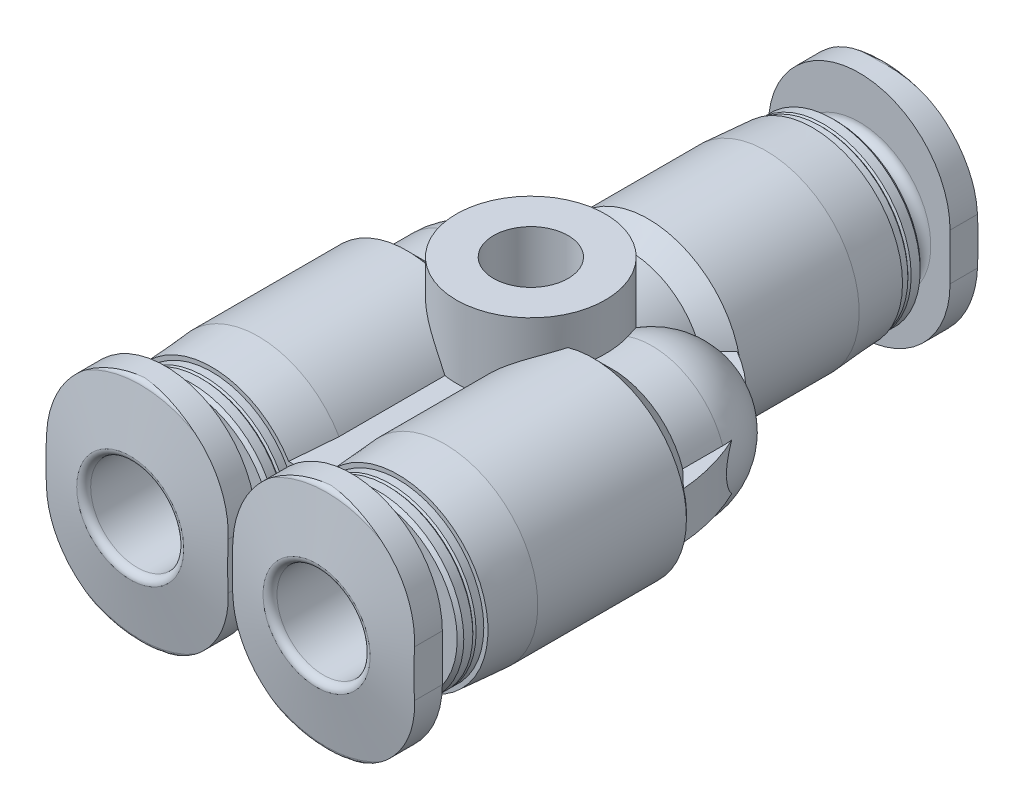
from build123d import *

# Parameters (mm, degrees)
BOSS_EXTRUDE1_DEPTH      = 2
BOSS_EXTRUDE1_DEPTH_BACK = 2
SKETCH3_W                = 6
SKETCH3_H                = 11.8
BOSS_EXTRUDE2_DEPTH      = 1
BOSS_EXTRUDE2_DEPTH_BACK = 1
SKETCH6_W                = 3.2
SKETCH6_H                = 10.2
SKETCH7_W                = 1.6
SKETCH7_H                = 10.2
SKETCH11_W               = 11.76
SKETCH11_H               = 11.76
CUT_EXTRUDE1_DEPTH       = 1.5
SKETCH12_W               = 19.76
SKETCH12_H               = 11.76
CUT_EXTRUDE2_DEPTH       = 1.5


with BuildPart() as part:
    # Sketch1 → Revolve1 (revolve)
    with BuildSketch(Plane(origin=(0, 0, 0), x_dir=(0, 0, -1), z_dir=(1, 0, 0))):
        with BuildLine():
            Line((0, 3.2), (4.24, 3.2))
            Line((4.24, 3.2), (5.04, 4))
            Line((5.04, 4), (10.1, 4))
            Line((10.1, 4), (12.1, 3.860146376))
            Line((12.1, 3.860146376), (12.1, 3.76))
            Line((12.1, 3.76), (12.429289322, 3.76))
            Line((12.429289322, 3.76), (12.5, 3.689289322))
            Line((12.5, 3.689289322), (12.570710678, 3.76))
            Line((12.570710678, 3.76), (12.958578644, 3.76))
            Line((12.958578644, 3.76), (13.1, 3.618578644))
            Line((13.1, 3.618578644), (13.1, 2.7))
            Line((13.1, 2.7), (13.725, 2.7))
            ThreePointArc((13.725, 2.7), (13.990165043, 2.809834957), (14.1, 3.075))
            Line((14.1, 3.075), (14.1, 4.9))
            Line((14.1, 4.9), (14.956097226, 4.9))
            ThreePointArc((14.956097226, 4.9), (15.084654748, 4.853208889), (15.153058776, 4.734729636))
            Line((15.153058776, 4.734729636), (15.6, 2.2))
            Line((15.6, 2.2), (15.6, 0))
            Line((15.6, 0), (-3.2, 0))
            ThreePointArc((-3.2, 0), (-2.2627417, 2.2627417), (0, 3.2))
        make_face()
    revolve(axis=Axis((0, 0, -15.6), (0, 0, 1)))

    # Sketch2 → Revolve2 (revolve)
    with BuildSketch(Plane(origin=(-4, 0, 0), x_dir=(0, 0, -1), z_dir=(1, 0, 0))):
        with BuildLine():
            Line((-13.2, 0), (-13.2, 2.3))
            Line((-13.2, 2.3), (-12.770691475, 4.734729636))
            ThreePointArc((-12.770691475, 4.734729636), (-12.702287446, 4.853208889), (-12.573729924, 4.9))
            Line((-12.573729924, 4.9), (-11.7, 4.9))
            Line((-11.7, 4.9), (-11.7, 3.075))
            ThreePointArc((-11.7, 3.075), (-11.590165043, 2.809834957), (-11.325, 2.7))
            Line((-11.325, 2.7), (-10.7, 2.7))
            Line((-10.7, 2.7), (-10.7, 3.538578644))
            Line((-10.7, 3.538578644), (-10.558578644, 3.68))
            Line((-10.558578644, 3.68), (-10.170710678, 3.68))
            Line((-10.170710678, 3.68), (-10.1, 3.609289322))
            Line((-10.1, 3.609289322), (-10.029289322, 3.68))
            Line((-10.029289322, 3.68), (-9.7, 3.68))
            Line((-9.7, 3.68), (-9.7, 3.860146376))
            Line((-9.7, 3.860146376), (-7.7, 4))
            Line((-7.7, 4), (-1.32, 4))
            Line((-1.32, 4), (-0.52, 3.2))
            Line((-0.52, 3.2), (1.2, 3.2))
            ThreePointArc((1.2, 3.2), (3.4627417, 2.2627417), (4.4, 0))
            Line((4.4, 0), (-13.2, 0))
        make_face()
    revolve(axis=Axis((-4, 0, -4.4), (0, 0, 1)))

    # Sketch3 → Boss-Extrude1 (add, two sides: drawn at the far end of the back side and taken through both)
    with BuildSketch(Plane(origin=(0, 0, 0), x_dir=(1, 0, 0), z_dir=(0, 1, 0)).offset(-BOSS_EXTRUDE1_DEPTH_BACK)):
        with Locations((0, -3.8)):
            Rectangle(SKETCH3_W, SKETCH3_H)
    extrude(amount=BOSS_EXTRUDE1_DEPTH + BOSS_EXTRUDE1_DEPTH_BACK)

    # Sketch4 → Revolve3 (revolve)
    with BuildSketch(Plane(origin=(4, 0, 0), x_dir=(0, 0, -1), z_dir=(1, 0, 0))):
        with BuildLine():
            Line((-13.2, 0), (-13.2, 2.3))
            Line((-13.2, 2.3), (-12.770691475, 4.734729636))
            ThreePointArc((-12.770691475, 4.734729636), (-12.702287446, 4.853208889), (-12.573729924, 4.9))
            Line((-12.573729924, 4.9), (-11.7, 4.9))
            Line((-11.7, 4.9), (-11.7, 3.075))
            ThreePointArc((-11.7, 3.075), (-11.590165043, 2.809834957), (-11.325, 2.7))
            Line((-11.325, 2.7), (-10.7, 2.7))
            Line((-10.7, 2.7), (-10.7, 3.538578644))
            Line((-10.7, 3.538578644), (-10.558578644, 3.68))
            Line((-10.558578644, 3.68), (-10.170710678, 3.68))
            Line((-10.170710678, 3.68), (-10.1, 3.609289322))
            Line((-10.1, 3.609289322), (-10.029289322, 3.68))
            Line((-10.029289322, 3.68), (-9.7, 3.68))
            Line((-9.7, 3.68), (-9.7, 3.860146376))
            Line((-9.7, 3.860146376), (-7.7, 4))
            Line((-7.7, 4), (-1.32, 4))
            Line((-1.32, 4), (-0.52, 3.2))
            Line((-0.52, 3.2), (1.2, 3.2))
            ThreePointArc((1.2, 3.2), (3.4627417, 2.2627417), (4.4, 0))
            Line((4.4, 0), (-13.2, 0))
        make_face()
    revolve(axis=Axis((4, 0, -4.4), (0, 0, 1)))

    # Sketch5 → Boss-Extrude2 (add, two sides: drawn at the far end of the back side and taken through both)
    with BuildSketch(Plane(origin=(0, 0, 0), x_dir=(1, 0, 0), z_dir=(0, 1, 0)).offset(-BOSS_EXTRUDE2_DEPTH_BACK)):
        with BuildLine():
            Line((-7.8, -1.32), (7.8, -1.32))
            ThreePointArc((7.8, -1.32), (6.596687611, 2.36106139), (3.8, 5.04))
            Line((3.8, 5.04), (-3.8, 5.04))
            ThreePointArc((-3.8, 5.04), (-6.596687611, 2.36106139), (-7.8, -1.32))
        make_face()
    extrude(amount=BOSS_EXTRUDE2_DEPTH + BOSS_EXTRUDE2_DEPTH_BACK)

    # Sketch6 → Revolve4 (revolve)
    with BuildSketch(Plane(origin=(0, 0, 0), x_dir=(0, 0, -1), z_dir=(1, 0, 0))):
        with Locations((1.6, 0)):
            Rectangle(SKETCH6_W, SKETCH6_H)
    revolve(axis=Axis((0, -5.1, 0), (0, 1, 0)))

    # Sketch7 → Cut-Revolve1 (revolve, cut)
    with BuildSketch(Plane(origin=(0, 0, 0), x_dir=(0, 0, -1), z_dir=(1, 0, 0))):
        with Locations((0.8, 0)):
            Rectangle(SKETCH7_W, SKETCH7_H)
    revolve(axis=Axis((0, -5.1, 0), (0, 1, 0)), mode=Mode.SUBTRACT)

    # Sketch8 → Cut-Revolve2 (revolve, cut)
    with BuildSketch(Plane(origin=(-4, 0, 0), x_dir=(0, 0, -1), z_dir=(1, 0, 0))):
        with BuildLine():
            Line((-13.2, 0), (-13.2, 2.3))
            ThreePointArc((-13.2, 2.3), (-13.112132034, 2.087867966), (-12.9, 2))
            Line((-12.9, 2), (-1.6, 2))
            Line((-1.6, 2), (-1.6, 0))
            Line((-1.6, 0), (-13.2, 0))
        make_face()
    revolve(axis=Axis((-4, 0, 1.6), (0, 0, 1)), mode=Mode.SUBTRACT)

    # Sketch9 → Cut-Revolve3 (revolve, cut)
    with BuildSketch(Plane(origin=(4, 0, 0), x_dir=(0, 0, -1), z_dir=(1, 0, 0))):
        with BuildLine():
            Line((-13.2, 0), (-13.2, 2.3))
            ThreePointArc((-13.2, 2.3), (-13.112132034, 2.087867966), (-12.9, 2))
            Line((-12.9, 2), (-1.6, 2))
            Line((-1.6, 2), (-1.6, 0))
            Line((-1.6, 0), (-13.2, 0))
        make_face()
    revolve(axis=Axis((4, 0, 1.6), (0, 0, 1)), mode=Mode.SUBTRACT)

    # Sketch10 → Cut-Revolve4 (revolve, cut)
    with BuildSketch(Plane(origin=(0, 0, 0), x_dir=(0, 0, -1), z_dir=(1, 0, 0))):
        with BuildLine():
            Line((4, 0), (4, 2))
            Line((4, 2), (15.3, 2))
            ThreePointArc((15.3, 2), (15.512132034, 2.087867966), (15.6, 2.3))
            Line((15.6, 2.3), (15.6, 0))
            Line((15.6, 0), (4, 0))
        make_face()
    revolve(axis=Axis((0, 0, -15.6), (0, 0, 1)), mode=Mode.SUBTRACT)

    # Sketch11 → Cut-Extrude1 (cut)
    with BuildSketch(Plane.XY.offset(-15.6)):
        Rectangle(SKETCH11_W, SKETCH11_H)
        with BuildLine():
            Line((3.9, -1), (3.9, 1))
            ThreePointArc((3.9, 1), (0, 4.9), (-3.9, 1))
            Line((-3.9, 1), (-3.9, -1))
            ThreePointArc((-3.9, -1), (0, -4.9), (3.9, -1))
        make_face(mode=Mode.SUBTRACT)
    extrude(amount=CUT_EXTRUDE1_DEPTH, mode=Mode.SUBTRACT)

    # Sketch12 → Cut-Extrude2 (cut)
    with BuildSketch(Plane.XY.offset(13.2)):
        Rectangle(SKETCH12_W, SKETCH12_H)
        with BuildLine():
            Line((7.9, -1), (7.9, 1))
            ThreePointArc((7.9, 1), (4, 4.9), (0.1, 1))
            Line((0.1, 1), (0.1, -1))
            ThreePointArc((0.1, -1), (4, -4.9), (7.9, -1))
        make_face(mode=Mode.SUBTRACT)
        with BuildLine():
            Line((-0.1, -1), (-0.1, 1))
            ThreePointArc((-0.1, 1), (-4, 4.9), (-7.9, 1))
            Line((-7.9, 1), (-7.9, -1))
            ThreePointArc((-7.9, -1), (-4, -4.9), (-0.1, -1))
        make_face(mode=Mode.SUBTRACT)
    extrude(amount=-CUT_EXTRUDE2_DEPTH, mode=Mode.SUBTRACT)


solid = part.part
